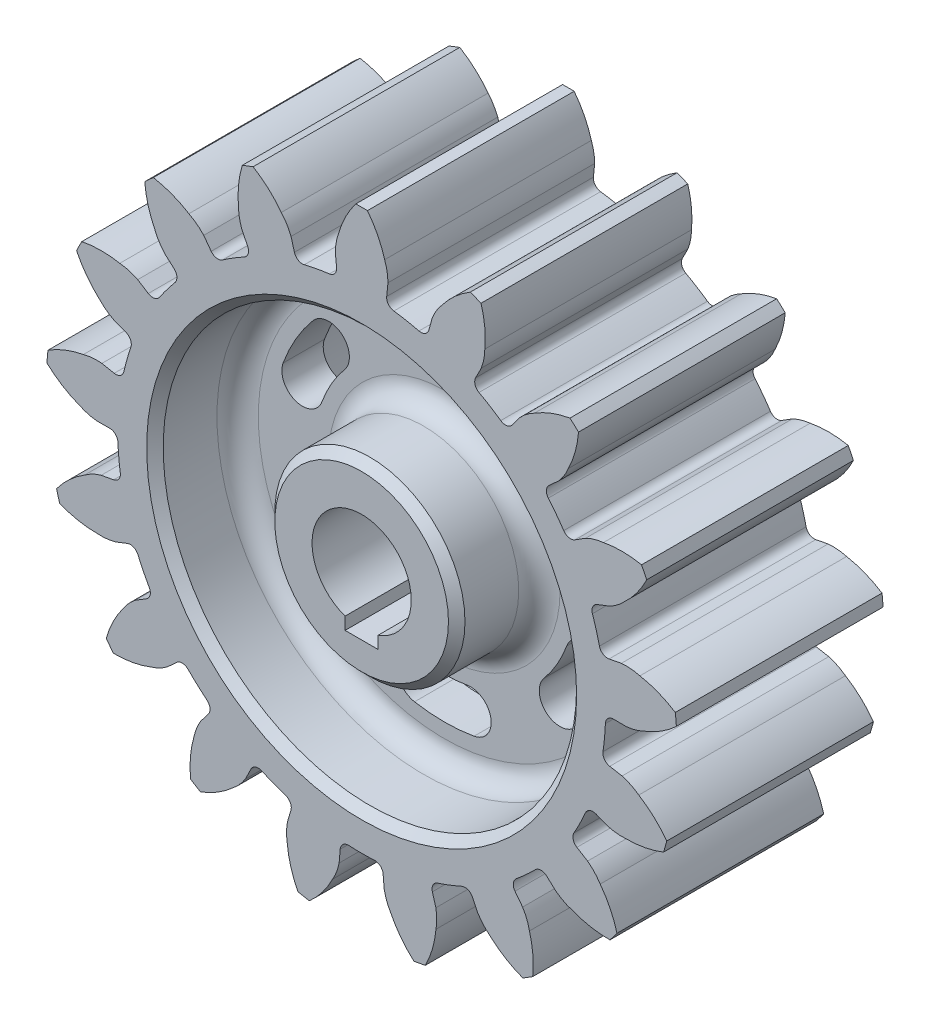
from build123d import *

# Parameters (mm, degrees)
ESBO_O1_R                    = 59
ESBO_O1_R_2                  = 50
RESSALTO_EXTRUS_O1_DEPTH     = 25
ESBO_O1_R_3                  = 23
RESSALTO_EXTRUS_O1_2_DEPTH   = 25
ESBO_O1_3_R                  = 50
ESBO_O1_3_R_2                = 23
RESSALTO_EXTRUS_O2_DEPTH     = 5
RESSALTO_EXTRUS_O3_DEPTH     = 25
FILETE1_R                    = 2
PADR_OCIRCULAR1_COUNT        = 17
FILETE1_OF_PADR_OCIRCULAR1_R = 2
CHANFRO2_SIZE                = 2
FILETE2_R                    = 5


with BuildPart() as part:
    # Esboço1 → Ressalto-extrusão1 (new, symmetric)
    with BuildSketch(Plane.XY):
        Circle(ESBO_O1_R)
        Circle(ESBO_O1_R_2, mode=Mode.SUBTRACT)
    extrude(amount=RESSALTO_EXTRUS_O1_DEPTH, both=True)



with BuildPart() as body_2:
    # Esboço1 → Ressalto-extrus_o1 2 (new, symmetric)
    with BuildSketch(Plane.XY):
        Circle(ESBO_O1_R_3)
        with BuildLine():
            Line((-4, -14.313708499), (-4, -11.313708499))
            ThreePointArc((-4, -11.313708499), (0, 12), (4, -11.313708499))
            Line((4, -11.313708499), (4, -14.313708499))
            Line((4, -14.313708499), (-4, -14.313708499))
        make_face(mode=Mode.SUBTRACT)
    extrude(amount=RESSALTO_EXTRUS_O1_2_DEPTH, both=True)


with BuildPart() as part_1:
    add(part.part)

    add(body_2.part)  # Ressalto-extrusão2 merges body 2
    # Esboço1<3> → Ressalto-extrusão2 (add, symmetric)
    with BuildSketch(Plane.XY):
        Circle(ESBO_O1_3_R)
        with BuildLine():
            ThreePointArc((-7.206399373, -40.86952175), (-11.26219725, -35.077242097), (-5.469917597, -31.02144422))
            ThreePointArc((-5.469917597, -31.02144422), (0, -31.5), (5.469917597, -31.02144422))
            ThreePointArc((5.469917597, -31.02144422), (11.26219725, -35.077242097), (7.206399373, -40.86952175))
            ThreePointArc((7.206399373, -40.86952175), (0, -41.5), (-7.206399373, -40.86952175))
        make_face(mode=Mode.SUBTRACT)
        with BuildLine():
            ThreePointArc((-38.997243763, -14.193835948), (-36.008881375, -7.785272127), (-29.600317555, -10.773634515))
            ThreePointArc((-29.600317555, -10.773634515), (-27.279800219, -15.75), (-24.130399958, -20.247809705))
            ThreePointArc((-24.130399958, -20.247809705), (-24.746684125, -27.291969969), (-31.790844389, -26.675685802))
            ThreePointArc((-31.790844389, -26.675685802), (-35.940054257, -20.75), (-38.997243763, -14.193835948))
        make_face(mode=Mode.SUBTRACT)
        Circle(ESBO_O1_3_R_2, mode=Mode.SUBTRACT)
        with BuildLine():
            ThreePointArc((31.790844389, -26.675685802), (24.746684125, -27.291969969), (24.130399958, -20.247809705))
            ThreePointArc((24.130399958, -20.247809705), (27.279800219, -15.75), (29.600317555, -10.773634515))
            ThreePointArc((29.600317555, -10.773634515), (36.008881375, -7.785272127), (38.997243763, -14.193835948))
            ThreePointArc((38.997243763, -14.193835948), (35.940054257, -20.75), (31.790844389, -26.675685802))
        make_face(mode=Mode.SUBTRACT)
        with BuildLine():
            ThreePointArc((-31.790844389, 26.675685802), (-24.746684125, 27.291969969), (-24.130399958, 20.247809705))
            ThreePointArc((-24.130399958, 20.247809705), (-27.279800219, 15.75), (-29.600317555, 10.773634515))
            ThreePointArc((-29.600317555, 10.773634515), (-36.008881375, 7.785272127), (-38.997243763, 14.193835948))
            ThreePointArc((-38.997243763, 14.193835948), (-35.940054257, 20.75), (-31.790844389, 26.675685802))
        make_face(mode=Mode.SUBTRACT)
        with BuildLine():
            ThreePointArc((-7.206399373, 40.86952175), (0, 41.5), (7.206399373, 40.86952175))
            ThreePointArc((7.206399373, 40.86952175), (11.26219725, 35.077242097), (5.469917597, 31.02144422))
            ThreePointArc((5.469917597, 31.02144422), (0, 31.5), (-5.469917597, 31.02144422))
            ThreePointArc((-5.469917597, 31.02144422), (-11.26219725, 35.077242097), (-7.206399373, 40.86952175))
        make_face(mode=Mode.SUBTRACT)
        with BuildLine():
            ThreePointArc((38.997243763, 14.193835948), (36.008881375, 7.785272127), (29.600317555, 10.773634515))
            ThreePointArc((29.600317555, 10.773634515), (27.279800219, 15.75), (24.130399958, 20.247809705))
            ThreePointArc((24.130399958, 20.247809705), (24.746684125, 27.291969969), (31.790844389, 26.675685802))
            ThreePointArc((31.790844389, 26.675685802), (35.940054257, 20.75), (38.997243763, 14.193835948))
        make_face(mode=Mode.SUBTRACT)
    extrude(amount=RESSALTO_EXTRUS_O2_DEPTH, both=True)

    # Esboço1<4> → Ressalto-extrusão3 (add, symmetric)
    with BuildSketch(Plane.XY):
        with BuildLine():
            ThreePointArc((-5.561184656, 68.113352767), (-6.159398106, 65.93412569), (-6.359997507, 63.683203686))
            Line((-6.359997507, 63.683203686), (-5.863122702, 58.707953398))
            ThreePointArc((-5.863122702, 58.707953398), (0, 59), (5.863122702, 58.707953398))
            Line((5.863122702, 58.707953398), (6.359997507, 63.683203686))
            ThreePointArc((6.359997507, 63.683203686), (6.159398106, 65.93412569), (5.561184656, 68.113352767))
            ThreePointArc((5.561184656, 68.113352767), (3.877416013, 72.420056886), (1.403980902, 76.327088492))
            ThreePointArc((1.403980902, 76.327088492), (0, 76.34), (-1.403980902, 76.327088492))
            ThreePointArc((-1.403980902, 76.327088492), (-3.877416013, 72.420056886), (-5.561184656, 68.113352767))
        make_face()
    ressalto_extrus_o3 = extrude(amount=RESSALTO_EXTRUS_O3_DEPTH, both=True)

    # Filete1
    filete1_edges = [part_1.edges().sort_by_distance(p)[0] for p in [
        (5.863122702, 58.707953398, 0),
        (-5.863122702, 58.707953398, 0),
    ]]
    fillet(filete1_edges, radius=FILETE1_R)

    # PadrãoCircular1: Ressalto-extrusão3 ×17 about axis
    padr_ocircular1_axis = Axis((0, 0, 25), (0, 0, 1))
    for i in range(1, PADR_OCIRCULAR1_COUNT):
        add(ressalto_extrus_o3.rotate(padr_ocircular1_axis, i * 360 / PADR_OCIRCULAR1_COUNT))

    # Filete1 of PadrãoCircular1
    filete1_of_padr_ocircular1_edges = [part_1.edges().sort_by_distance(p)[0] for p in [
        (-15.740559807, 56.861540403, 0),
        (-26.674958001, 52.625531975, 0),
        (-35.218392492, 47.335661295, 0),
        (-43.884192411, 39.435740851, 0),
        (-49.93978612, 31.416838834, 0),
        (-55.166623465, 20.919934403, 0),
        (-57.916534906, 11.254998202, 0),
        (-58.998496332, -0.421225107, 0),
        (-58.071334726, -10.426892304, 0),
        (-54.862295347, -21.705495832, 0),
        (-50.383279007, -30.700573227, 0),
        (-43.316637373, -40.05831907, 0),
        (-35.890682275, -46.827971617, 0),
        (-25.920827495, -53.001044348, 0),
        (-16.550850025, -56.630992958, 0),
        (-5.024266233, -58.785684897, 0),
        (5.024266233, -58.785684897, 0),
        (16.550850025, -56.630992958, 0),
        (25.920827495, -53.001044348, 0),
        (35.890682275, -46.827971617, 0),
        (43.316637373, -40.05831907, 0),
        (50.383279007, -30.700573227, 0),
        (54.862295347, -21.705495832, 0),
        (58.071334726, -10.426892304, 0),
        (58.998496332, -0.421225107, 0),
        (57.916534906, 11.254998202, 0),
        (55.166623465, 20.919934403, 0),
        (49.93978612, 31.416838834, 0),
        (43.884192411, 39.435740851, 0),
        (35.218392492, 47.335661295, 0),
        (26.674958001, 52.625531975, 0),
        (15.740559807, 56.861540403, 0),
    ]]
    fillet(filete1_of_padr_ocircular1_edges, radius=FILETE1_OF_PADR_OCIRCULAR1_R)

    # Chanfro2
    chanfro2_edges = [part_1.edges().sort_by_distance(p)[0] for p in [
        (-23, 0, 25),
        (-50, 0, 25),
        (-23, 0, -25),
        (-50, 0, -25),
    ]]
    chamfer(chanfro2_edges, length=CHANFRO2_SIZE)

    # Filete2
    filete2_edges = [part_1.edges().sort_by_distance(p)[0] for p in [
        (-50, 0, 5),
        (-50, 0, -5),
        (-23, 0, 5),
        (-23, 0, -5),
    ]]
    fillet(filete2_edges, radius=FILETE2_R)


solid = part_1.part
